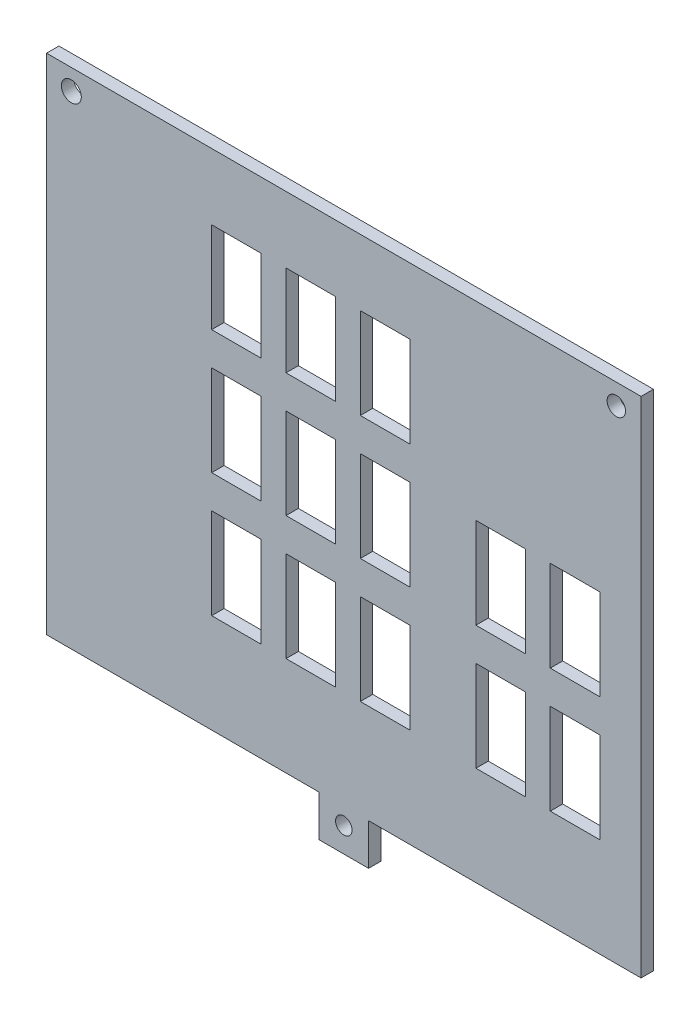
from build123d import *

# Parameters (mm, degrees)
ESQUISSE1_W             = 72
ESQUISSE1_H             = 61
BOSS_EXTRU_1_DEPTH      = 1.5
ESQUISSE2_R             = 1.114499423
ESQUISSE2_R_2           = 1.207075002
ENL_V_MAT_EXTRU_1_DEPTH = 76.344588982
ESQUISSE4_W             = 6
ESQUISSE4_H             = 11
ENL_V_MAT_EXTRU_2_DEPTH = 76.344588982
ESQUISSE4_3_W           = 6
ESQUISSE4_3_H           = 11
ESQUISSE4_3_H_2         = 10.972423644
ENL_V_MAT_EXTRU_3_DEPTH = 76.344588982
ESQUISSE5_W             = 6
ESQUISSE5_H             = 1.5
BOSS_EXTRU_2_DEPTH      = 5
ESQUISSE6_R             = 1
ENL_V_MAT_EXTRU_4_DEPTH = 6


with BuildPart() as part:
    # Esquisse1 → Boss.-Extru.1 (new body)
    with BuildSketch(Plane.XY):
        with Locations((-31.584952854, -2.769073276)):
            Rectangle(ESQUISSE1_W, ESQUISSE1_H)
    extrude(amount=BOSS_EXTRU_1_DEPTH)

    # Esquisse2 → Enl_v. mat.-Extru.1 (cut, through all)
    with BuildSketch(Plane(origin=(0, 0, 0), x_dir=(-1, 0, 0), z_dir=(0, 0, -1))):
        with Locations((-1.415047146, 25.230926724)):
            Circle(ESQUISSE2_R)
        with Locations((64.584952854, 25.230926724)):
            Circle(ESQUISSE2_R_2)
    extrude(amount=-ENL_V_MAT_EXTRU_1_DEPTH, mode=Mode.SUBTRACT)

    # Esquisse4 → Enl_v. mat.-Extru.2 (cut, through all)
    with BuildSketch(Plane(origin=(0, 0, 0), x_dir=(-1, 0, 0), z_dir=(0, 0, -1))):
        with Locations((44.584952854, -15.769073276)):
            Rectangle(ESQUISSE4_W, ESQUISSE4_H)
        with Locations((35.584952854, -15.769073276)):
            Rectangle(ESQUISSE4_W, ESQUISSE4_H)
    extrude(amount=-ENL_V_MAT_EXTRU_2_DEPTH, mode=Mode.SUBTRACT)

    # Esquisse4_3 → Enl_v. mat.-Extru.3 (cut, through all)
    with BuildSketch(Plane(origin=(0, 0, 0), x_dir=(-1, 0, 0), z_dir=(0, 0, -1))):
        with Locations((26.584952854, -15.769073276)):
            Rectangle(ESQUISSE4_3_W, ESQUISSE4_3_H)
        with Locations((26.584952854, 14.230926724)):
            Rectangle(ESQUISSE4_3_W, ESQUISSE4_3_H)
        with Locations((44.584952854, -15.769073276)):
            Rectangle(ESQUISSE4_3_W, ESQUISSE4_3_H)
        with Locations((35.584952854, -15.769073276)):
            Rectangle(ESQUISSE4_3_W, ESQUISSE4_3_H)
        with Locations((44.584952854, -0.769073276)):
            Rectangle(ESQUISSE4_3_W, ESQUISSE4_3_H)
        with Locations((35.584952854, -0.782861454)):
            Rectangle(ESQUISSE4_3_W, ESQUISSE4_3_H_2)
        with Locations((26.584952854, -0.769073276)):
            Rectangle(ESQUISSE4_3_W, ESQUISSE4_3_H)
        with Locations((35.584952854, 14.203350368)):
            Rectangle(ESQUISSE4_3_W, ESQUISSE4_3_H)
        with Locations((44.584952854, 14.230926724)):
            Rectangle(ESQUISSE4_3_W, ESQUISSE4_3_H)
        with Locations((12.584952854, -15.769073276)):
            Rectangle(ESQUISSE4_3_W, ESQUISSE4_3_H)
        with Locations((3.584952854, -15.769073276)):
            Rectangle(ESQUISSE4_3_W, ESQUISSE4_3_H)
        with Locations((12.584952854, -0.769073276)):
            Rectangle(ESQUISSE4_3_W, ESQUISSE4_3_H)
        with Locations((3.584952854, -0.769073276)):
            Rectangle(ESQUISSE4_3_W, ESQUISSE4_3_H)
    extrude(amount=-ENL_V_MAT_EXTRU_3_DEPTH, mode=Mode.SUBTRACT)

    # Esquisse5 → Boss.-Extru.2 (add)
    with BuildSketch(Plane.XZ.offset(33.269073276)):
        with Locations((-31.584952854, 0.75)):
            Rectangle(ESQUISSE5_W, ESQUISSE5_H)
    extrude(amount=BOSS_EXTRU_2_DEPTH)

    # Esquisse6 → Enl_v. mat.-Extru.4 (cut)
    with BuildSketch(Plane.XY.offset(1.5)):
        with Locations((-31.584952854, -35.269073276)):
            Circle(ESQUISSE6_R)
    extrude(amount=-ENL_V_MAT_EXTRU_4_DEPTH, mode=Mode.SUBTRACT)


solid = part.part
